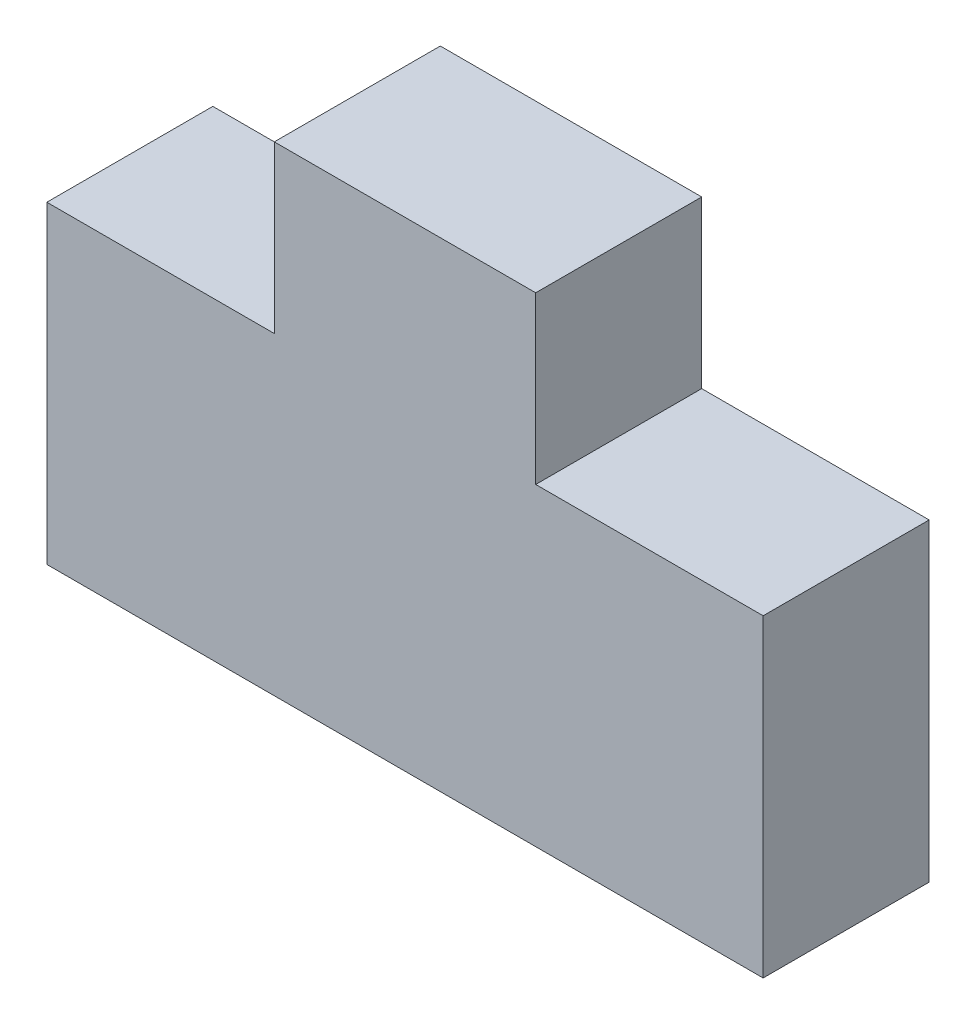
from build123d import *

# Parameters (mm, degrees)
SKETCH1_W           = 27.4
SKETCH1_H           = 6.35
BOSS_EXTRUDE1_DEPTH = 12
SKETCH2_W           = 10
SKETCH2_H           = 6.35
BOSS_EXTRUDE2_DEPTH = 6.35


with BuildPart() as part:
    # Sketch1 → Boss-Extrude1 (new body)
    with BuildSketch(Plane(origin=(0, 0, 0), x_dir=(1, 0, 0), z_dir=(0, 1, 0))):
        with Locations((13.7, 3.175)):
            Rectangle(SKETCH1_W, SKETCH1_H)
    extrude(amount=BOSS_EXTRUDE1_DEPTH)

    # Sketch2 → Boss-Extrude2 (add)
    with BuildSketch(Plane.XY):
        with Locations((13.7, 15.175)):
            Rectangle(SKETCH2_W, SKETCH2_H)
    extrude(amount=-BOSS_EXTRUDE2_DEPTH)


solid = part.part
